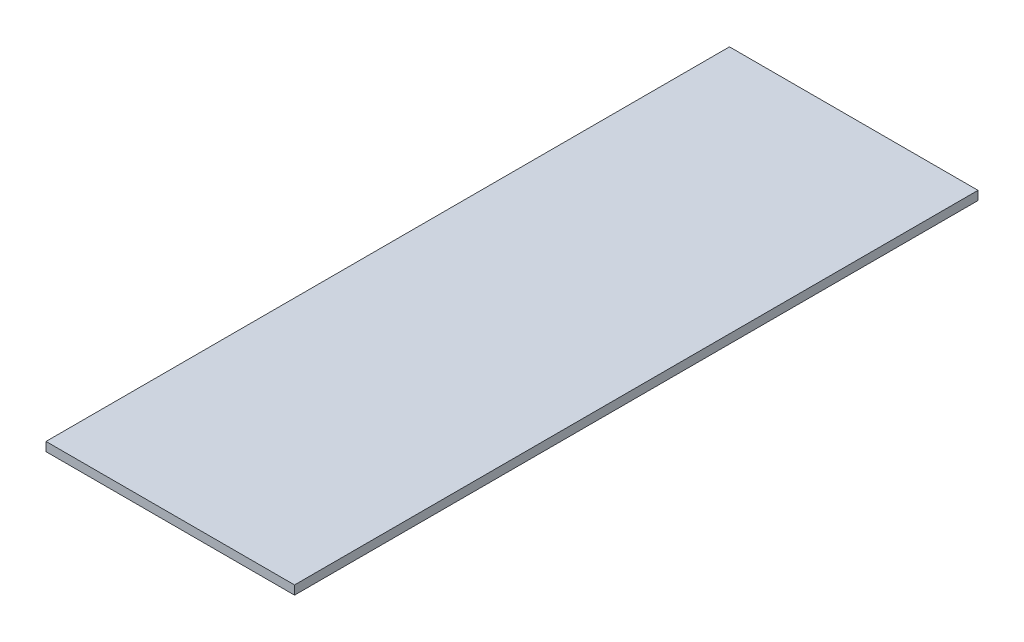
from build123d import *

# Parameters (mm, degrees)
SKETCH1_W           = 56
SKETCH1_H           = 154
BOSS_EXTRUDE1_DEPTH = 2


with BuildPart() as part:
    # Sketch1 → Boss-Extrude1 (new body)
    with BuildSketch(Plane(origin=(0, 0, 0), x_dir=(1, 0, 0), z_dir=(0, 1, 0))):
        Rectangle(SKETCH1_W, SKETCH1_H)
    extrude(amount=BOSS_EXTRUDE1_DEPTH)


solid = part.part
